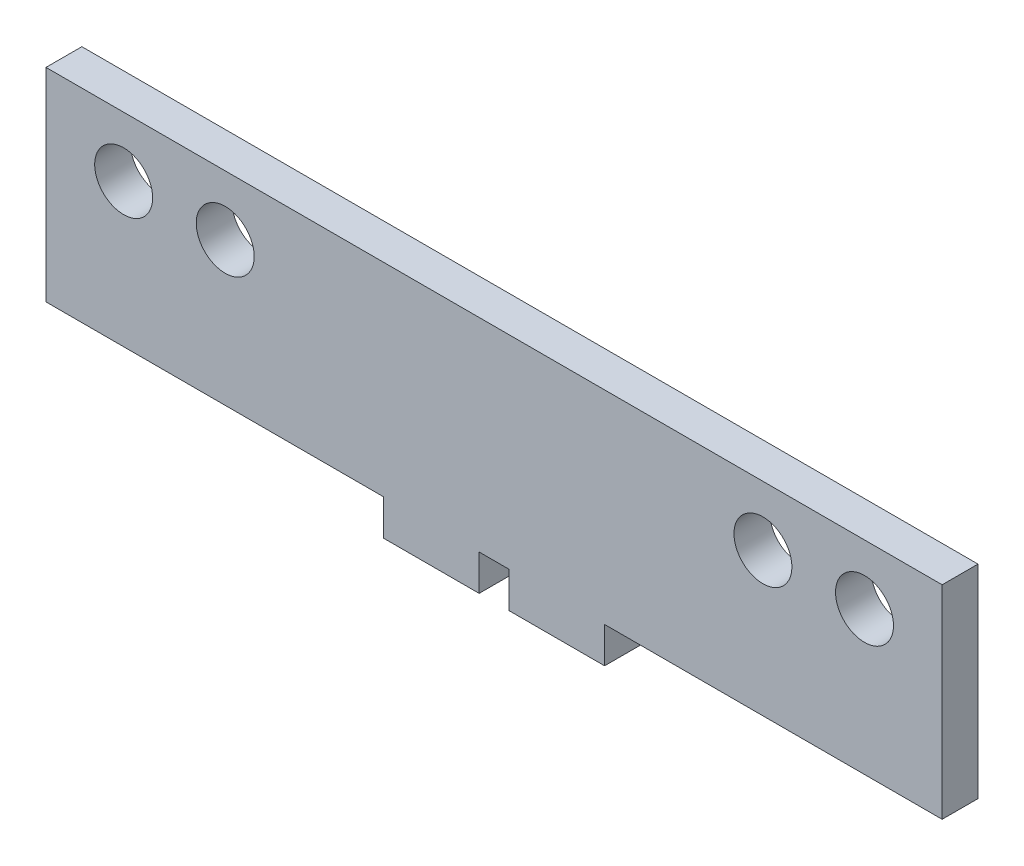
from build123d import *

# Parameters (mm, degrees)
SKETCH1_W           = 75
SKETCH1_H           = 17
BOSS_EXTRUDE1_DEPTH = 3
SKETCH2_W           = 8
SKETCH2_H           = 3
BOSS_EXTRUDE2_DEPTH = 3
SKETCH3_R           = 2.425
CUT_EXTRUDE1_DEPTH  = 3


with BuildPart() as part:
    # Sketch1 → Boss-Extrude1 (new body)
    with BuildSketch(Plane.XY):
        Rectangle(SKETCH1_W, SKETCH1_H)
    extrude(amount=BOSS_EXTRUDE1_DEPTH)

    # Sketch2 → Boss-Extrude2 (add)
    with BuildSketch(Plane(origin=(0, -8.5, 0), x_dir=(-1, 0, 0), z_dir=(0, -1, 0))):
        with Locations((5.25, -1.5)):
            Rectangle(SKETCH2_W, SKETCH2_H)
        with Locations((-5.25, -1.5)):
            Rectangle(SKETCH2_W, SKETCH2_H)
    extrude(amount=BOSS_EXTRUDE2_DEPTH)

    # Sketch3 → Cut-Extrude1 (cut)
    with BuildSketch(Plane.XY.offset(3)):
        with Locations((-31, 3.5)):
            Circle(SKETCH3_R)
        with Locations((-22.5, 3.5)):
            Circle(SKETCH3_R)
        with Locations((22.5, 3.5)):
            Circle(SKETCH3_R)
        with Locations((31, 3.5)):
            Circle(SKETCH3_R)
    extrude(amount=-CUT_EXTRUDE1_DEPTH, mode=Mode.SUBTRACT)


solid = part.part
